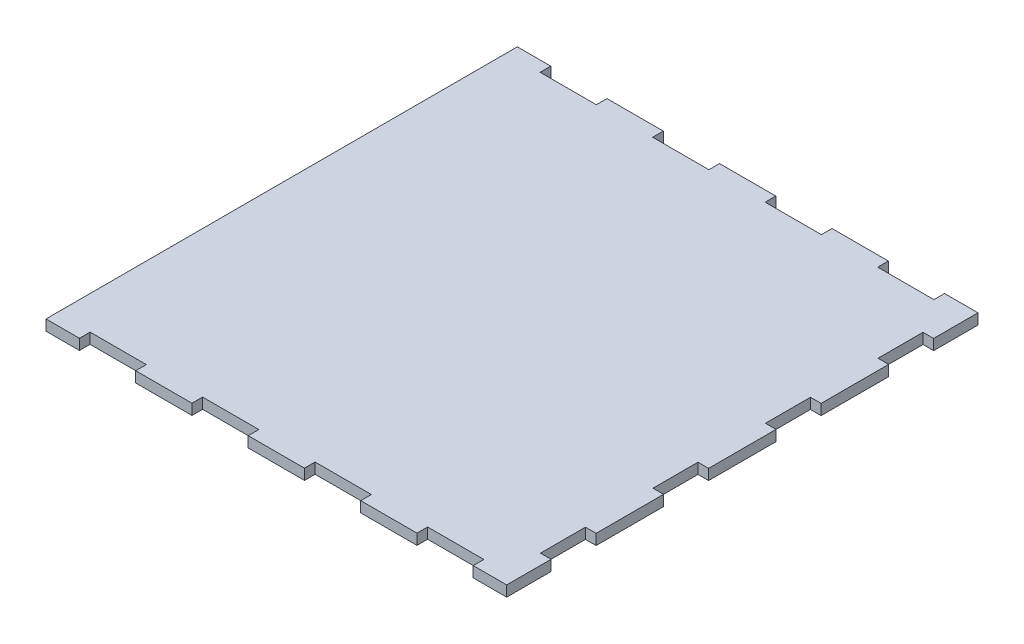
from build123d import *

# Parameters (mm, degrees)
SKETCH1_W           = 260
SKETCH1_H           = 266
BOSS_EXTRUDE1_DEPTH = 6
SKETCH2_W           = 31.75
SKETCH2_H           = 6
SKETCH2_W_2         = 6
SKETCH2_H_2         = 25.4
TAB_CUT_OUTS_DEPTH  = 6


with BuildPart() as part:
    # Sketch1 → Boss-Extrude1 (new body)
    with BuildSketch(Plane(origin=(0, 0, 0), x_dir=(1, 0, 0), z_dir=(0, 1, 0))):
        Rectangle(SKETCH1_W, SKETCH1_H)
    extrude(amount=BOSS_EXTRUDE1_DEPTH)

    # Sketch2 → Tab Cut Outs (cut)
    with BuildSketch(Plane(origin=(0, 6, 0), x_dir=(1, 0, 0), z_dir=(0, 1, 0))):
        with Locations((95.25, 130)):
            Rectangle(SKETCH2_W, SKETCH2_H)
        with Locations((-31.75, 130)):
            Rectangle(SKETCH2_W, SKETCH2_H)
        with Locations((-95.25, 130)):
            Rectangle(SKETCH2_W, SKETCH2_H)
        with Locations((31.75, 130)):
            Rectangle(SKETCH2_W, SKETCH2_H)
        with Locations((31.75, -130)):
            Rectangle(SKETCH2_W, SKETCH2_H)
        with Locations((95.25, -130)):
            Rectangle(SKETCH2_W, SKETCH2_H)
        with Locations((-95.25, -130)):
            Rectangle(SKETCH2_W, SKETCH2_H)
        with Locations((-31.75, -130)):
            Rectangle(SKETCH2_W, SKETCH2_H)
        with Locations((127, -95.25)):
            Rectangle(SKETCH2_W_2, SKETCH2_H_2)
        with Locations((127, 31.75)):
            Rectangle(SKETCH2_W_2, SKETCH2_H_2)
        with Locations((127, 95.25)):
            Rectangle(SKETCH2_W_2, SKETCH2_H_2)
        with Locations((127, -31.75)):
            Rectangle(SKETCH2_W_2, SKETCH2_H_2)
    extrude(amount=-TAB_CUT_OUTS_DEPTH, mode=Mode.SUBTRACT)


solid = part.part
